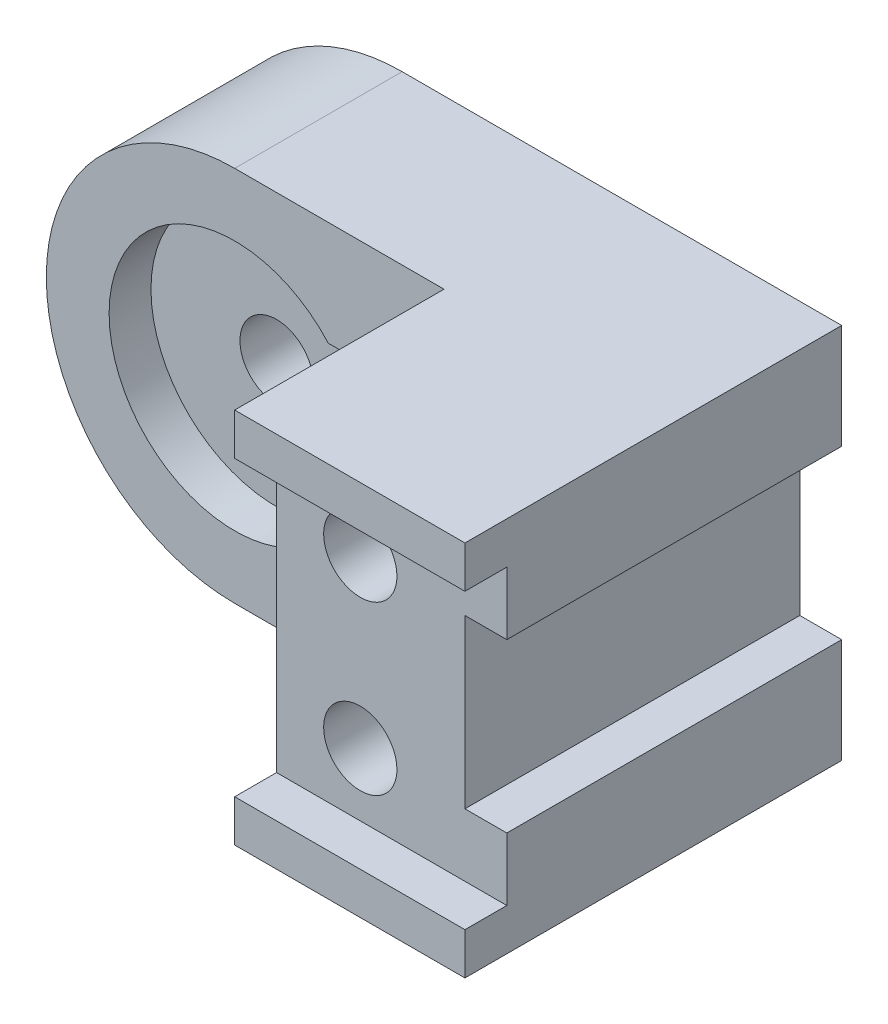
from build123d import *

# Parameters (mm, degrees)
SKETCH1_W              = 150
SKETCH1_H              = 90
BOSS_EXTRUDE1_DEPTH    = 90
SKETCH2_W              = 10
SKETCH2_H              = 40
CUT_EXTRUDE1_DEPTH     = 90
CUT_EXTRUDE2_DEPTH     = 90
CUT_EXTRUDE3_DEPTH     = 10
CUT_EXTRUDE4_DEPTH     = 50
SKETCH6_W              = 10
SKETCH6_H              = 70
CUT_EXTRUDE6_DEPTH     = 94
SKETCH7_R              = 30
CUT_EXTRUDE8_DEPTH     = 10
M20_TAPPED_HOLE2_D     = 17.5
M20_TAPPED_HOLE2_DEPTH = 25
M20_TAPPED_HOLE2_TIP   = 5.257530416
M20_TAPPED_HOLE3_D     = 17.5
M20_TAPPED_HOLE3_DEPTH = 37.5
M20_TAPPED_HOLE3_TIP   = 5.257530416


with BuildPart() as part:
    # Sketch1 → Boss-Extrude1 (new body)
    with BuildSketch(Plane.XY):
        with Locations((75, 45)):
            Rectangle(SKETCH1_W, SKETCH1_H)
    extrude(amount=BOSS_EXTRUDE1_DEPTH)

    # Sketch2 → Cut-Extrude1 (cut)
    with BuildSketch(Plane.XY.offset(90)):
        with Locations((145, 45)):
            Rectangle(SKETCH2_W, SKETCH2_H)
    extrude(amount=-CUT_EXTRUDE1_DEPTH, mode=Mode.SUBTRACT)

    # Sketch3 → Cut-Extrude2 (cut)
    with BuildSketch(Plane.XY.offset(90)):
        with BuildLine():
            ThreePointArc((0, 45), (13.180194847, 76.819805153), (45, 90))
            Line((45, 90), (0, 90))
            Line((0, 90), (0, 45))
        make_face()
        with BuildLine():
            ThreePointArc((45, 0), (13.180194847, 13.180194847), (0, 45))
            Line((0, 45), (0, 0))
            Line((0, 0), (45, 0))
        make_face()
    extrude(amount=-CUT_EXTRUDE2_DEPTH, mode=Mode.SUBTRACT)

    # Sketch4 → Cut-Extrude3 (cut)
    with BuildSketch(Plane(origin=(0, 0, 0), x_dir=(-1, 0, 0), z_dir=(0, 0, -1))):
        with BuildLine():
            ThreePointArc((-11.458980338, 15), (0, 45), (-11.458980338, 75))
            Line((-11.458980338, 75), (-45, 75))
            ThreePointArc((-45, 75), (-75, 45), (-45, 15))
            Line((-45, 15), (-11.458980338, 15))
        make_face()
    extrude(amount=-CUT_EXTRUDE3_DEPTH, mode=Mode.SUBTRACT)

    # Sketch5 → Cut-Extrude4 (cut)
    with BuildSketch(Plane.XY.offset(90)):
        with BuildLine():
            Line((95, 90), (95, 0))
            Line((95, 0), (45, 0))
            ThreePointArc((45, 0), (0, 45), (45, 90))
            Line((45, 90), (95, 90))
        make_face()
    extrude(amount=-CUT_EXTRUDE4_DEPTH, mode=Mode.SUBTRACT)

    # Sketch6 → Cut-Extrude6 (cut)
    with BuildSketch(Plane.ZY.offset(-95)):
        with Locations((85, 45)):
            Rectangle(SKETCH6_W, SKETCH6_H)
    extrude(amount=-CUT_EXTRUDE6_DEPTH, mode=Mode.SUBTRACT)

    # Sketch7 → Cut-Extrude8 (cut)
    with BuildSketch(Plane.XY.offset(40)):
        with Locations((45, 45)):
            Circle(SKETCH7_R)
        with BuildLine():
            Line((95, 65), (67.360679775, 65))
            ThreePointArc((67.360679775, 65), (73.025170769, 55.704662693), (75, 45))
            ThreePointArc((75, 45), (73.025170769, 34.295337307), (67.360679775, 25))
            Line((67.360679775, 25), (95, 25))
            Line((95, 25), (95, 65))
        make_face()
    extrude(amount=-CUT_EXTRUDE8_DEPTH, mode=Mode.SUBTRACT)

    # M20 Tapped Hole2
    with Locations(Plane(origin=(115, 65, 80), x_dir=(0, 1, 0), z_dir=(0, 0, 1))):
        with Locations((0, 0), (-40, 0)):
            Hole(M20_TAPPED_HOLE2_D / 2, depth=M20_TAPPED_HOLE2_DEPTH)
            with Locations((0, 0, -(M20_TAPPED_HOLE2_DEPTH + M20_TAPPED_HOLE2_TIP / 2))):  # 118° drill point
                Cone(0, M20_TAPPED_HOLE2_D / 2, M20_TAPPED_HOLE2_TIP, mode=Mode.SUBTRACT)

    # M20 Tapped Hole3
    with Locations(Plane(origin=(45, 45, 40), x_dir=(1, 0, 0), z_dir=(0, 0, 1))):
        with Locations((0, 0)):
            Hole(M20_TAPPED_HOLE3_D / 2, depth=M20_TAPPED_HOLE3_DEPTH)
            with Locations((0, 0, -(M20_TAPPED_HOLE3_DEPTH + M20_TAPPED_HOLE3_TIP / 2))):  # 118° drill point
                Cone(0, M20_TAPPED_HOLE3_D / 2, M20_TAPPED_HOLE3_TIP, mode=Mode.SUBTRACT)


solid = part.part
